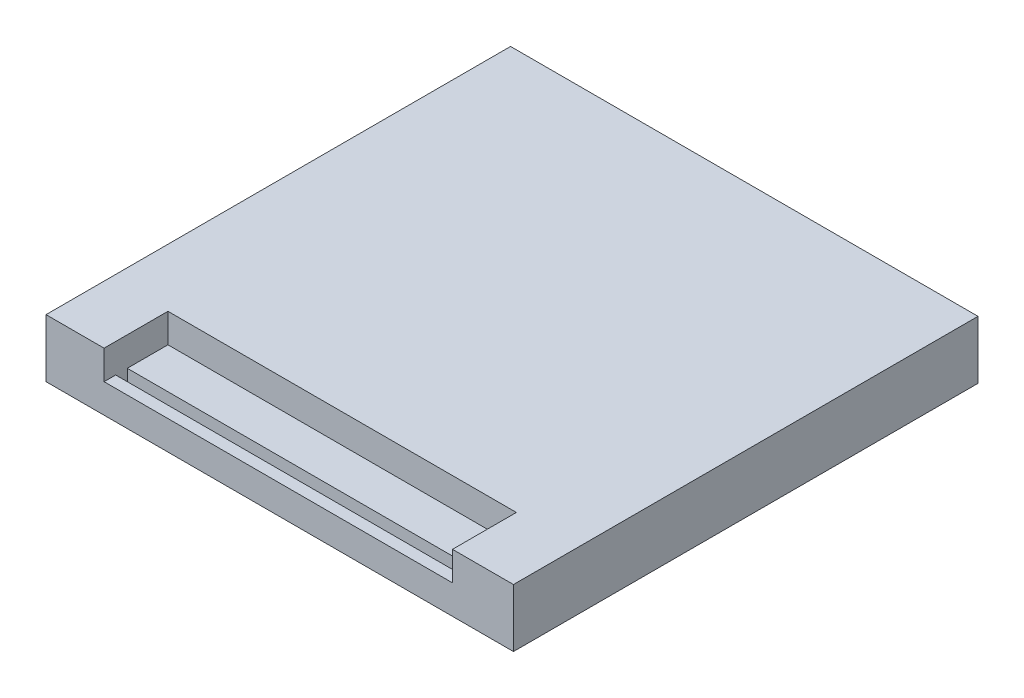
from build123d import *

# Parameters (mm, degrees)
SKETCH1_W           = 80.5
SKETCH1_H           = 80
BOSS_EXTRUDE1_DEPTH = 10
CUT_EXTRUDE1_START  = -10
SKETCH2_W           = 11
SKETCH2_H           = 5
CUT_EXTRUDE1_DEPTH  = 60
CUT_EXTRUDE2_START  = -10
SKETCH3_W           = 2
SKETCH3_H           = 2
CUT_EXTRUDE2_DEPTH  = 60


with BuildPart() as part:
    # Sketch1 → Boss-Extrude1 (new body)
    with BuildSketch(Plane(origin=(0, 0, 0), x_dir=(1, 0, 0), z_dir=(0, 1, 0))):
        Rectangle(SKETCH1_W, SKETCH1_H)
    extrude(amount=BOSS_EXTRUDE1_DEPTH)

    # Sketch2 → Cut-Extrude1 (cut)
    with BuildSketch(Plane.ZY.offset(40.25).offset(CUT_EXTRUDE1_START)):
        with Locations((34.5, 7.5)):
            Rectangle(SKETCH2_W, SKETCH2_H)
    extrude(amount=-CUT_EXTRUDE1_DEPTH, mode=Mode.SUBTRACT)

    # Sketch3 → Cut-Extrude2 (cut)
    with BuildSketch(Plane.ZY.offset(40.25).offset(CUT_EXTRUDE2_START)):
        with Locations((37, 4)):
            Rectangle(SKETCH3_W, SKETCH3_H)
    extrude(amount=-CUT_EXTRUDE2_DEPTH, mode=Mode.SUBTRACT)


solid = part.part
